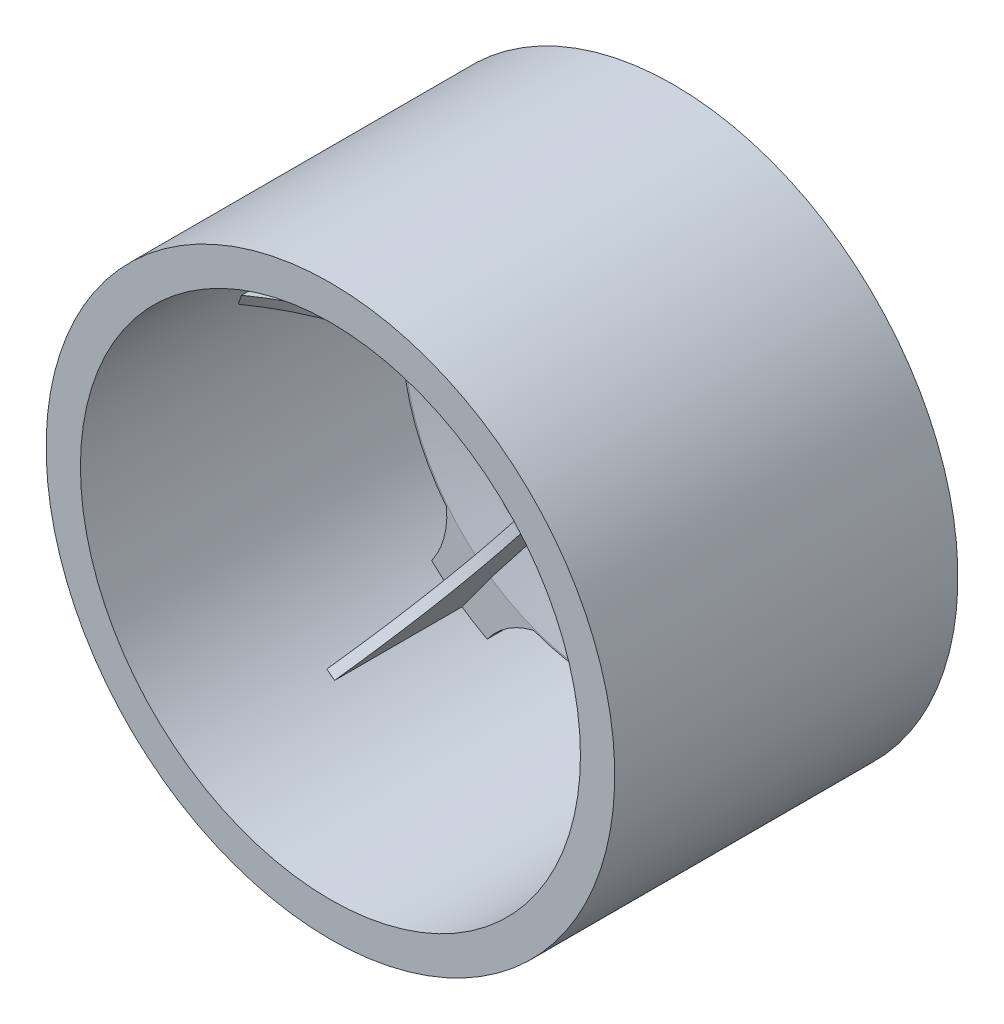
from build123d import *

# Parameters (mm, degrees)
BOSS_EXTRU_3_DEPTH            = 0.5
BOSS_EXTRU_3_2_DEPTH          = 0.5
ENL_V_MAT_EXTRU_1_DEPTH       = 1.5
R_P_TITION_CIRCULAIRE3_COUNT  = 5
R_P_TITION_CIRCULAIRE14_COUNT = 5
ENL_V_MAT_EXTRU_2_DEPTH       = 4
ENL_V_START                   = -14.426909
ESQUISSE7_R                   = 1.5
ENL_V_MAT_EXTRU_3_DEPTH       = 14.426909


with BuildPart() as part:
    # Esquisse1 → Révolution1 (revolve)
    with BuildSketch(Plane(origin=(0, 0, 0), x_dir=(0, 0, -1), z_dir=(1, 0, 0))):
        Polygon((0, 0), (-4, 0), (-4, 8.5), (-1, 8.5), (1.5, 13.5), (0, 20.5), (0, 25.5), (-28, 25.5), (-28, 29), (7, 29), (7, 25.5), (1.5, 25.5), (1.5, 20.658910532), (3.218138528, 12.640930736), (1.673026606, 9.550706893), (4.4269094, 7), (4.4269094, 5), (1.4269094, 5), (1.4269094, 0), align=None)
    revolve(axis=Axis((0, 0, 0), (0, 0, 1)))

    # Esquisse4 → Enlèv. mat.-Extru.1 (cut)
    with BuildSketch(Plane(origin=(0, 0, -1.5), x_dir=(-1, 0, 0), z_dir=(0, 0, -1))):
        with BuildLine():
            ThreePointArc((-3.5, 25.258661881), (-14.988523933, 20.629933357), (-22.940855494, 11.134053583))
            add(Edge.make_bspline(
                [(-17.239105748, 11.384367236), (-20.00963633, 10.232558106), (-22.940855494, 11.134053583)],
                knots=[0, 0, 0, 1, 1, 1], degree=2))
            ThreePointArc((-17.239105748, 11.384367236), (-12.143002939, 16.713409705), (-5.5, 19.913326803))
            add(Edge.make_bspline(
                [(-5.5, 19.913326803), (-3.548423388, 22.192329371), (-3.5, 25.258661881)],
                knots=[0, 0, 0, 1, 1, 1], degree=2))
        make_face()
    enl_v_mat_extru_1 = extrude(amount=-ENL_V_MAT_EXTRU_1_DEPTH, mode=Mode.SUBTRACT)

    # Répétition circulaire3: Enlèv. mat.-Extru.1 ×5 about axis
    r_p_tition_circulaire3_axis = Axis((0, 0, 0), (0, 0, -1))
    for i in range(1, R_P_TITION_CIRCULAIRE3_COUNT):
        add(enl_v_mat_extru_1.rotate(r_p_tition_circulaire3_axis, i * 360 / R_P_TITION_CIRCULAIRE3_COUNT), mode=Mode.SUBTRACT)

    # Esquisse6 → Enlèv. mat.-Extru.2 (cut)
    with BuildSketch(Plane.XY.offset(4)):
        Polygon((3.464101615, 6), (-3.464101615, 6), (-6.92820323, 0), (-3.464101615, -6), (3.464101615, -6), (6.92820323, 0), align=None)
    extrude(amount=-ENL_V_MAT_EXTRU_2_DEPTH, mode=Mode.SUBTRACT)

    # Esquisse7 → Enlèv. mat.-Extru.3 (cut)
    with BuildSketch(Plane(origin=(0, 0, -1.4269094), x_dir=(-1, 0, 0), z_dir=(0, 0, -1)).offset(ENL_V_START)):
        Circle(ESQUISSE7_R)
    extrude(amount=ENL_V_MAT_EXTRU_3_DEPTH, mode=Mode.SUBTRACT)


with BuildPart() as body_2:
    # Esquisse3 → Boss.-Extru.3 (new body, symmetric)
    with BuildSketch(Plane(origin=(0, 0, 0), x_dir=(0, 0, -1), z_dir=(1, 0, 0))):
        with BuildLine():
            Line((-1, 8.5), (-3, 8.5))
            add(Edge.make_bspline(
                [(-3, 8.5), (-4.687060249, 18.6059753), (-13, 25.5)],
                knots=[0, 0, 0, 1, 1, 1], degree=2))
            Line((-13, 25.5), (0, 25.5))
            Line((0, 25.5), (0, 20.5))
            Line((0, 20.5), (1.5, 13.5))
            Line((1.5, 13.5), (-1, 8.5))
        make_face()
    extrude(amount=BOSS_EXTRU_3_DEPTH, both=True)


with BuildPart() as body_3:
    # Esquisse3 → Boss.-Extru.3 2 (new body, symmetric)
    with BuildSketch(Plane(origin=(0, 0, 0), x_dir=(0, 0, -1), z_dir=(1, 0, 0))):
        Polygon((4.4269094, 7), (3.218138528, 12.640930736), (1.673026606, 9.550706893), align=None)
    extrude(amount=BOSS_EXTRU_3_2_DEPTH, both=True)


with BuildPart() as r_p_tition_circulaire14_1:
    # Répétition circulaire14: pattern copy
    add(body_2.part.rotate(Axis((0, 0, 0), (0, 0, -1)), 1 * 360 / R_P_TITION_CIRCULAIRE14_COUNT))


with BuildPart() as r_p_tition_circulaire14_2:
    # Répétition circulaire14: pattern copy
    add(body_2.part.rotate(Axis((0, 0, 0), (0, 0, -1)), 2 * 360 / R_P_TITION_CIRCULAIRE14_COUNT))


with BuildPart() as r_p_tition_circulaire14_3:
    # Répétition circulaire14: pattern copy
    add(body_2.part.rotate(Axis((0, 0, 0), (0, 0, -1)), 3 * 360 / R_P_TITION_CIRCULAIRE14_COUNT))


with BuildPart() as r_p_tition_circulaire14_4:
    # Répétition circulaire14: pattern copy
    add(body_2.part.rotate(Axis((0, 0, 0), (0, 0, -1)), 4 * 360 / R_P_TITION_CIRCULAIRE14_COUNT))


with BuildPart() as r_p_tition_circulaire14_5:
    # Répétition circulaire14: pattern copy
    add(body_3.part.rotate(Axis((0, 0, 0), (0, 0, -1)), 1 * 360 / R_P_TITION_CIRCULAIRE14_COUNT))


with BuildPart() as r_p_tition_circulaire14_6:
    # Répétition circulaire14: pattern copy
    add(body_3.part.rotate(Axis((0, 0, 0), (0, 0, -1)), 2 * 360 / R_P_TITION_CIRCULAIRE14_COUNT))


with BuildPart() as r_p_tition_circulaire14_7:
    # Répétition circulaire14: pattern copy
    add(body_3.part.rotate(Axis((0, 0, 0), (0, 0, -1)), 3 * 360 / R_P_TITION_CIRCULAIRE14_COUNT))


with BuildPart() as r_p_tition_circulaire14_8:
    # Répétition circulaire14: pattern copy
    add(body_3.part.rotate(Axis((0, 0, 0), (0, 0, -1)), 4 * 360 / R_P_TITION_CIRCULAIRE14_COUNT))


solid = Compound([part.part, body_2.part, body_3.part, r_p_tition_circulaire14_1.part, r_p_tition_circulaire14_2.part, r_p_tition_circulaire14_3.part, r_p_tition_circulaire14_4.part, r_p_tition_circulaire14_5.part, r_p_tition_circulaire14_6.part, r_p_tition_circulaire14_7.part, r_p_tition_circulaire14_8.part])
